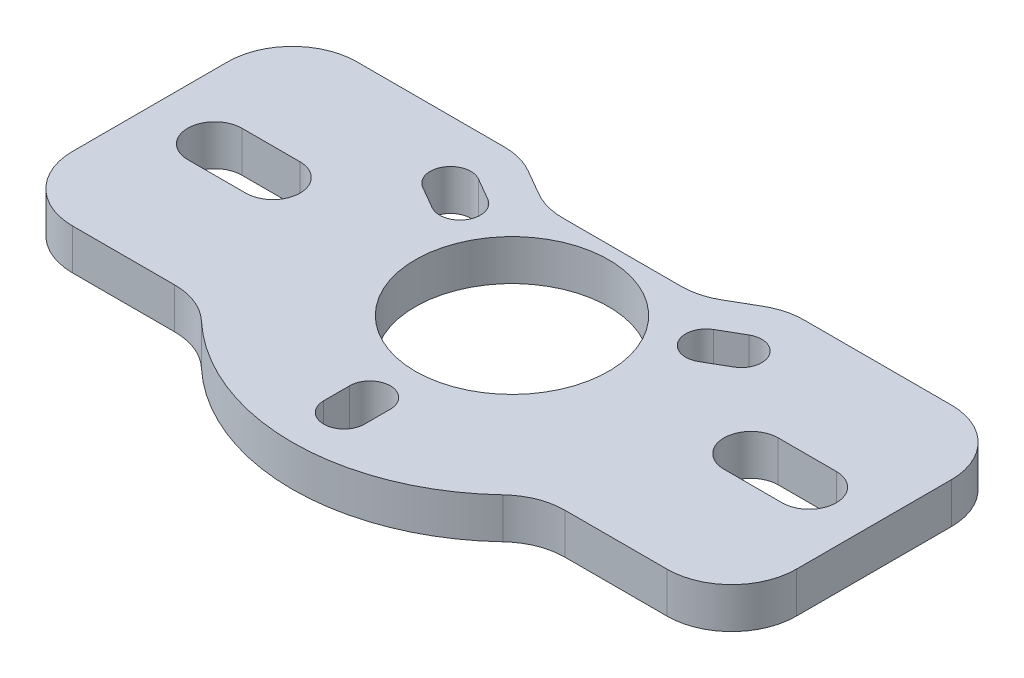
from build123d import *

# Parameters (mm, degrees)
SKETCH1_R           = 5.75
BOSS_EXTRUDE1_DEPTH = 4
SKETCH6_R           = 9.5
CUT_EXTRUDE1_DEPTH  = 5


with BuildPart() as part:
    # Sketch1 → Boss-Extrude1 (new body)
    with BuildSketch(Plane(origin=(0, 0, 0), x_dir=(1, 0, 0), z_dir=(0, 1, 0))):
        with BuildLine():
            Line((14.722227154, 13.97), (29.21, 13.97))
            ThreePointArc((29.21, 13.97), (33.700128061, 12.110128061), (35.56, 7.62))
            Line((35.56, 7.62), (35.56, -7.62))
            ThreePointArc((35.56, -7.62), (33.700128061, -12.110128061), (29.21, -13.97))
            Line((29.21, -13.97), (19.176579466, -13.97))
            ThreePointArc((19.176579466, -13.97), (16.831686562, -14.418815604), (14.818265951, -15.701818182))
            ThreePointArc((14.818265951, -15.701818182), (0, -21.59), (-14.818265951, -15.701818182))
            ThreePointArc((-14.818265951, -15.701818182), (-16.831686562, -14.418815604), (-19.176579466, -13.97))
            Line((-19.176579466, -13.97), (-29.21, -13.97))
            ThreePointArc((-29.21, -13.97), (-33.700128061, -12.110128061), (-35.56, -7.62))
            Line((-35.56, -7.62), (-35.56, 7.62))
            ThreePointArc((-35.56, 7.62), (-33.700128061, 12.110128061), (-29.21, 13.97))
            Line((-29.21, 13.97), (-14.722227154, 13.97))
            ThreePointArc((-14.722227154, 13.97), (-13.078726217, 13.753628997), (-11.547227154, 13.119261314))
            Line((-11.547227154, 13.119261314), (-8.995011096, 11.645738686))
            ThreePointArc((-8.995011096, 11.645738686), (-7.463512032, 11.011371003), (-5.820011096, 10.795))
            Line((-5.820011096, 10.795), (5.820011096, 10.795))
            ThreePointArc((5.820011096, 10.795), (7.463512032, 11.011371003), (8.995011096, 11.645738686))
            Line((8.995011096, 11.645738686), (11.547227154, 13.119261314))
            ThreePointArc((11.547227154, 13.119261314), (13.078726217, 13.753628997), (14.722227154, 13.97))
        make_face()
        Circle(SKETCH1_R, mode=Mode.SUBTRACT)
        with BuildLine():
            Line((-23.495, -2.667), (-29.21, -2.667))
            ThreePointArc((-29.21, -2.667), (-31.877, 0), (-29.21, 2.667))
            Line((-29.21, 2.667), (-23.495, 2.667))
            ThreePointArc((-23.495, 2.667), (-20.828, 0), (-23.495, -2.667))
        make_face(mode=Mode.SUBTRACT)
        with BuildLine():
            Line((23.495, 2.667), (29.21, 2.667))
            ThreePointArc((29.21, 2.667), (31.877, 0), (29.21, -2.667))
            Line((29.21, -2.667), (23.495, -2.667))
            ThreePointArc((23.495, -2.667), (20.828, 0), (23.495, 2.667))
        make_face(mode=Mode.SUBTRACT)
        with BuildLine():
            Line((-15.289419162, 6.517949192), (-13.089714637, 5.247949192))
            ThreePointArc((-13.089714637, 5.247949192), (-10.357663829, 5.98), (-11.089714637, 8.712050808))
            Line((-11.089714637, 8.712050808), (-13.289419162, 9.982050808))
            ThreePointArc((-13.289419162, 9.982050808), (-16.02146997, 9.25), (-15.289419162, 6.517949192))
        make_face(mode=Mode.SUBTRACT)
        with BuildLine():
            Line((13.289419162, 9.982050808), (11.089714637, 8.712050808))
            ThreePointArc((11.089714637, 8.712050808), (10.357663829, 5.98), (13.089714637, 5.247949192))
            Line((13.089714637, 5.247949192), (15.289419162, 6.517949192))
            ThreePointArc((15.289419162, 6.517949192), (16.02146997, 9.25), (13.289419162, 9.982050808))
        make_face(mode=Mode.SUBTRACT)
        with BuildLine():
            Line((2, -16.5), (2, -13.96))
            ThreePointArc((2, -13.96), (0, -11.96), (-2, -13.96))
            Line((-2, -13.96), (-2, -16.5))
            ThreePointArc((-2, -16.5), (0, -18.5), (2, -16.5))
        make_face(mode=Mode.SUBTRACT)
    extrude(amount=BOSS_EXTRUDE1_DEPTH)

    # Sketch6 → Cut-Extrude1 (cut, through all)
    with BuildSketch(Plane(origin=(0, 4, 0), x_dir=(1, 0, 0), z_dir=(0, 1, 0))):
        Circle(SKETCH6_R)
    extrude(amount=-CUT_EXTRUDE1_DEPTH, mode=Mode.SUBTRACT)


solid = part.part
